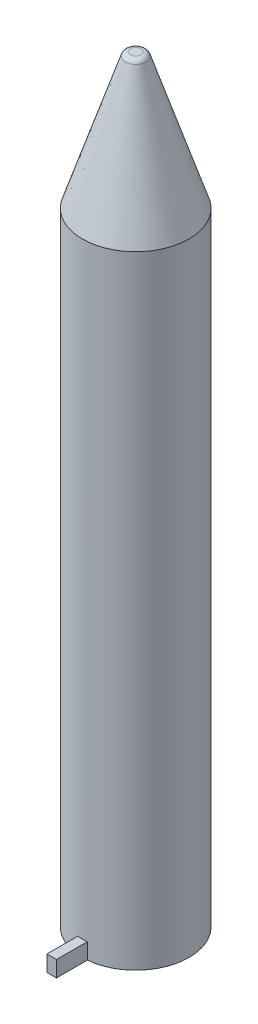
from build123d import *

# Parameters (mm, degrees)
SKETCH1_R           = 10
BOSS_EXTRUDE1_DEPTH = 116.650008
BOSS_EXTRUDE2_DEPTH = 3
SKETCH4_R           = 6
CUT_EXTRUDE1_DEPTH  = 3


with BuildPart() as part:
    # Sketch1 → Boss-Extrude1 (new body)
    with BuildSketch(Plane(origin=(0, 0, 0), x_dir=(1, 0, 0), z_dir=(0, 1, 0))):
        Circle(SKETCH1_R)
    extrude(amount=BOSS_EXTRUDE1_DEPTH)

    # Sketch2 → Revolve1 (revolve)
    with BuildSketch(Plane.XY):
        with BuildLine():
            Line((0, 116.650008), (0, 142.050008))
            Line((0, 142.050008), (1, 142.050008))
            ThreePointArc((1, 142.050008), (1.587481775, 141.859245397), (1.950824444, 141.359738328))
            Line((1.950824444, 141.359738328), (10, 116.650008))
            Line((10, 116.650008), (0, 116.650008))
        make_face()
    revolve(axis=Axis((0, 116.650008, 0), (0, 1, 0)))

    # Sketch3 → Boss-Extrude2 (add)
    with BuildSketch(Plane.XZ):
        with BuildLine():
            Line((-0.9, 15.75), (0.9, 15.75))
            Line((0.9, 15.75), (0.9, 9.354806465))
            ThreePointArc((0.9, 9.354806465), (0, 9.398), (-0.9, 9.354806465))
            Line((-0.9, 9.354806465), (-0.9, 15.75))
        make_face()
    extrude(amount=-BOSS_EXTRUDE2_DEPTH)

    # Sketch4 → Cut-Extrude1 (cut)
    with BuildSketch(Plane.XZ):
        Circle(SKETCH4_R)
    extrude(amount=-CUT_EXTRUDE1_DEPTH, mode=Mode.SUBTRACT)


solid = part.part
